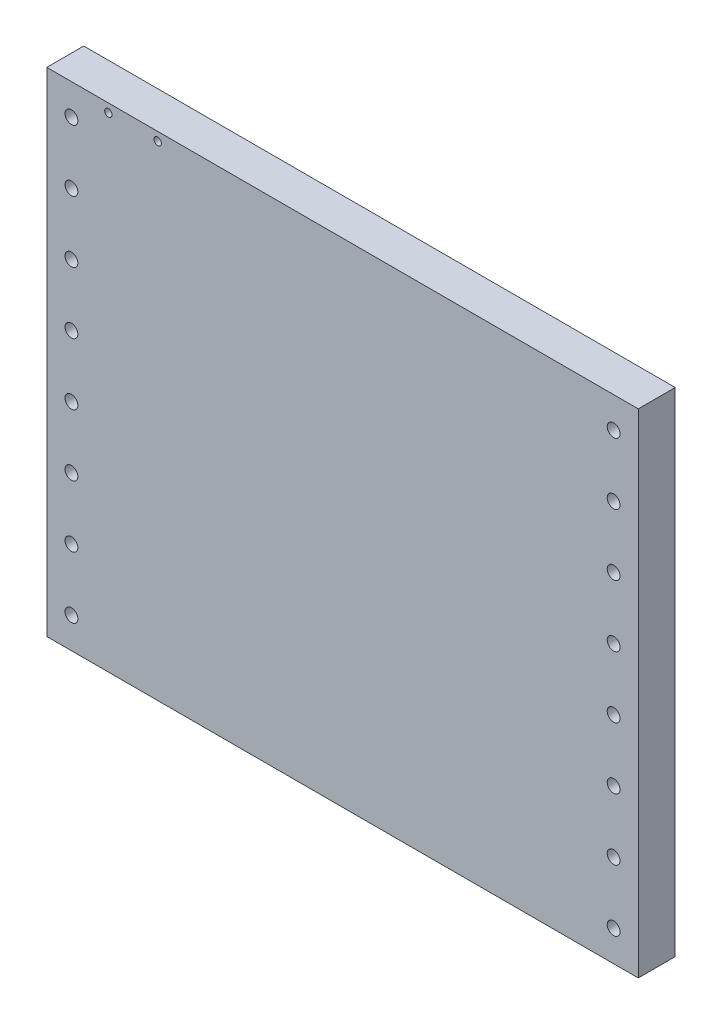
from build123d import *

# Parameters (mm, degrees)
SKETCH1_W           = 240
SKETCH1_H           = 200
BOSS_EXTRUDE1_DEPTH = 7.5
SKETCH4_R           = 2.6
CUT_EXTRUDE3_DEPTH  = 16
LPATTERN1_COUNT     = 8
LPATTERN1_PITCH     = 25
SKETCH5_R           = 1.5
CUT_EXTRUDE4_DEPTH  = 16


with BuildPart() as part:
    # Sketch1 → Boss-Extrude1 (new body, symmetric)
    with BuildSketch(Plane.XY):
        Rectangle(SKETCH1_W, SKETCH1_H)
    extrude(amount=BOSS_EXTRUDE1_DEPTH, both=True)

    # Sketch4 → Cut-Extrude3 (cut, through all)
    with BuildSketch(Plane.XY.offset(7.5)):
        with Locations((-110, 87.5)):
            Circle(SKETCH4_R)
        with Locations((110, 87.5)):
            Circle(SKETCH4_R)
    cut_extrude3 = extrude(amount=-CUT_EXTRUDE3_DEPTH, mode=Mode.SUBTRACT)

    # LPattern1: Cut-Extrude3 ×8
    with Locations(*[(0, -i * LPATTERN1_PITCH, 0) for i in range(1, LPATTERN1_COUNT)]):
        add(cut_extrude3, mode=Mode.SUBTRACT)

    # Sketch5 → Cut-Extrude4 (cut, through all)
    with BuildSketch(Plane.XY.offset(7.5)):
        with Locations((-95, 96.5)):
            Circle(SKETCH5_R)
        with Locations((-75, 96.5)):
            Circle(SKETCH5_R)
    extrude(amount=-CUT_EXTRUDE4_DEPTH, mode=Mode.SUBTRACT)


solid = part.part
